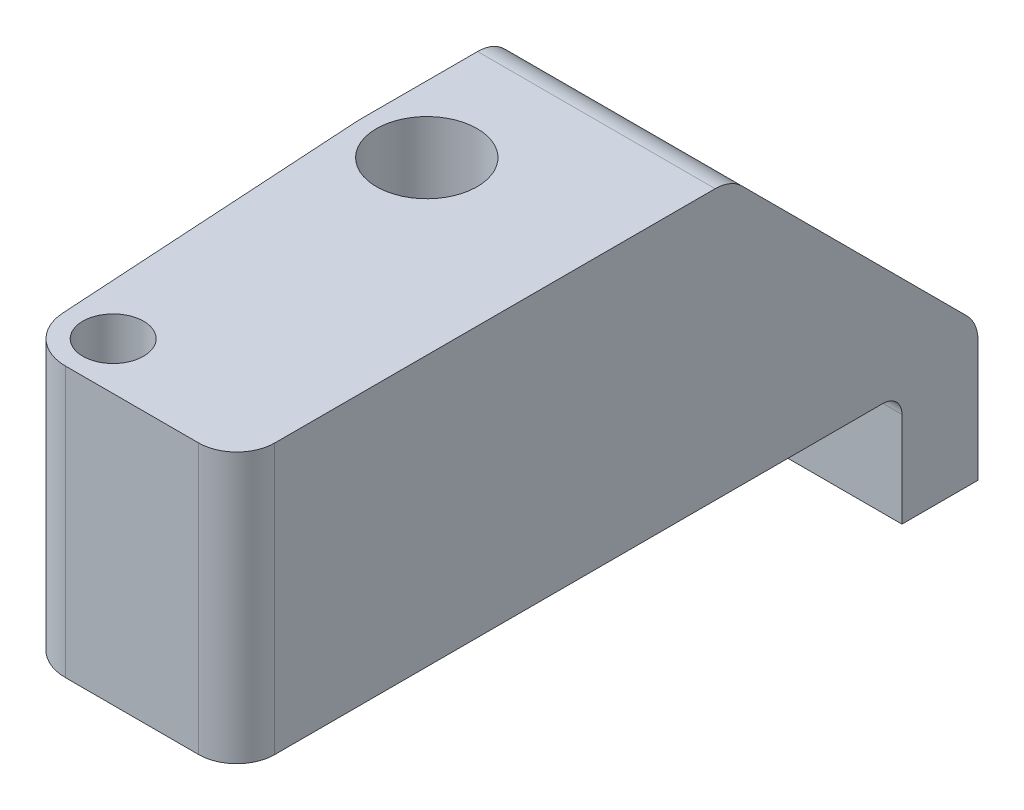
from build123d import *

# Parameters (mm, degrees)
SKETCH1_W                = 7
SKETCH1_H                = 16
SKETCH1_W_2              = 3.5
BOSS_EXTRUDE1_DEPTH      = 14.2
M3_CLEARANCE_HOLE1_D     = 3.2
M5_CLEARANCE_HOLE1_D     = 5.3
SKETCH6_W                = 14.632471907
SKETCH6_H                = 4
BOSS_EXTRUDE2_DEPTH      = 6
BOSS_EXTRUDE2_DEPTH_BACK = 14.2
FILLET1_R                = 1
FILLET2_R                = 2
SKETCH7_W                = 8.569742994
SKETCH7_H                = 13.514047563
CUT_EXTRUDE1_DEPTH       = 10
CHAMFER1_SIZE            = 13
FILLET4_R                = 2


with BuildPart() as part:
    # Sketch1 → Boss-Extrude1 (new body)
    with BuildSketch(Plane(origin=(0, 0, 0), x_dir=(1, 0, 0), z_dir=(0, 1, 0))):
        with BuildLine():
            Line((-3.5, 16.5), (3.5, 16.5))
            ThreePointArc((3.5, 16.5), (3.498391173, 16.393890619), (3.493566171, 16.287878788))
            Line((3.493566171, 16.287878788), (2.495404408, -0.151515152))
            ThreePointArc((2.495404408, -0.151515152), (0, -2.5), (-2.495404408, -0.151515152))
            Line((-2.495404408, -0.151515152), (-3.493566171, 16.287878788))
            ThreePointArc((-3.493566171, 16.287878788), (-3.498391173, 16.393890619), (-3.5, 16.5))
        make_face()
        with Locations((0, 24.5)):
            Rectangle(SKETCH1_W, SKETCH1_H)
        with BuildLine():
            ThreePointArc((2.495404408, -0.151515152), (1.713361042, -1.820547703), (0, -2.5))
            Line((0, -2.5), (9, -2.5))
            Line((9, -2.5), (9, 32.5))
            Line((9, 32.5), (3.5, 32.5))
            Line((3.5, 32.5), (3.5, 16.5))
            ThreePointArc((3.5, 16.5), (3.498391173, 16.393890619), (3.493566171, 16.287878788))
            Line((3.493566171, 16.287878788), (2.495404408, -0.151515152))
        make_face()
        with BuildLine():
            Line((0, 16.5), (0, -2.5))
            ThreePointArc((0, -2.5), (1.713361042, -1.820547703), (2.495404408, -0.151515152))
            Line((2.495404408, -0.151515152), (3.493566171, 16.287878788))
            ThreePointArc((3.493566171, 16.287878788), (3.498391173, 16.393890619), (3.5, 16.5))
            Line((3.5, 16.5), (0, 16.5))
        make_face()
        with Locations((1.75, 24.5)):
            Rectangle(SKETCH1_W_2, SKETCH1_H)
    extrude(amount=BOSS_EXTRUDE1_DEPTH)

    # M3 Clearance Hole1 (through all)
    with Locations(Plane(origin=(0, 0, 0), x_dir=(-1, 0, 0), z_dir=(0, -1, 0))):
        with Locations((0, 0)):
            Hole(M3_CLEARANCE_HOLE1_D / 2)

    # M5 Clearance Hole1 (through all)
    with Locations(Plane(origin=(0, 0, 0), x_dir=(-1, 0, 0), z_dir=(0, -1, 0))):
        with Locations((0, 16.5)):
            Hole(M5_CLEARANCE_HOLE1_D / 2)

    # Sketch6 → Boss-Extrude2 (add, two sides)
    with BuildSketch(Plane.XZ) as boss_extrude2_sk:
        with Locations((1.683764046, -34.5)):
            Rectangle(SKETCH6_W, SKETCH6_H)
    extrude(amount=BOSS_EXTRUDE2_DEPTH)
    extrude(boss_extrude2_sk.sketch, amount=-BOSS_EXTRUDE2_DEPTH_BACK)

    # Fillet1
    fillet1_edges = [part.edges().sort_by_distance(p)[0] for p in [
        (2.75, 0, -32.5),
    ]]
    fillet(fillet1_edges, radius=FILLET1_R)

    # Fillet2
    fillet2_edges = [part.edges().sort_by_distance(p)[0] for p in [
        (9, 7.1, 2.5),
    ]]
    fillet(fillet2_edges, radius=FILLET2_R)

    # Sketch7 → Cut-Extrude1 (cut)
    with BuildSketch(Plane.XZ):
        with Locations((-7.784871497, -36.46322787)):
            Rectangle(SKETCH7_W, SKETCH7_H)
    extrude(amount=-CUT_EXTRUDE1_DEPTH, mode=Mode.SUBTRACT)

    # Chamfer1
    chamfer1_edges = [part.edges().sort_by_distance(p)[0] for p in [
        (1.683764046, 14.2, -36.5),
    ]]
    chamfer(chamfer1_edges, length=CHAMFER1_SIZE)

    # Fillet4
    fillet4_edges = [part.edges().sort_by_distance(p)[0] for p in [
        (2.75, 1.2, -36.5),
        (2.75, 14.2, -23.5),
    ]]
    fillet(fillet4_edges, radius=FILLET4_R)


solid = part.part
